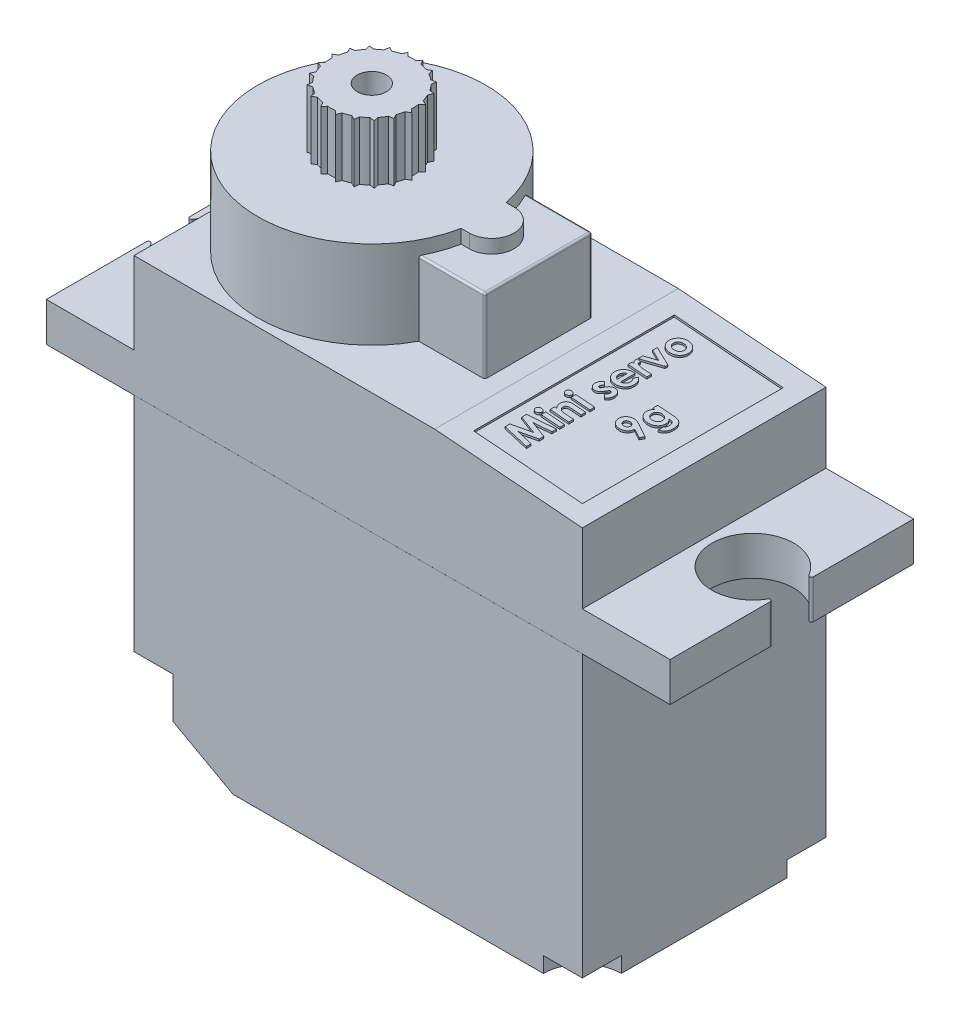
from build123d import *

# Parameters (mm, degrees)
SKETCH1_W                    = 23
SKETCH1_H                    = 12.5
BOSS_EXTRUDE1_DEPTH          = 15.2
SKETCH2_W                    = 32
SKETCH2_H                    = 12.498058614
BOSS_EXTRUDE2_DEPTH          = 2
SKETCH3_W                    = 23
SKETCH3_H                    = 12.498058614
BOSS_EXTRUDE3_DEPTH          = 4.2
CUT_EXTRUDE1_DEPTH           = 13.5
BOSS_EXTRUDE4_DEPTH          = 4.5
SKETCH6_W                    = 4.8
SKETCH6_H                    = 5.5
BOSS_EXTRUDE5_DEPTH          = 3.8
SKETCH8_R                    = 2.35
SKETCH8_R_2                  = 0.75
BOSS_EXTRUDE8_DEPTH          = 3
CUT_EXTRUDE2_DEPTH           = 13.5
ENL_V_MAT_EXTRU_1_DEPTH      = 3
R_P_TITION_CIRCULAIRE2_COUNT = 20
SKETCH12_R                   = 2.1
CUT_EXTRUDE11_DEPTH          = 10
CUT_EXTRUDE12_DEPTH          = 0.8
CUT_EXTRUDE13_DEPTH          = 3.8
SKETCH17_W                   = 5.6
SKETCH17_H                   = 10.3
CUT_EXTRUDE14_DEPTH          = 0.1
SKETCH19_W                   = 0.966746795
SKETCH19_H                   = 0.237446581
BOSS_EXTRUDE9_DEPTH          = 0.1
FILLET3_R                    = 0.1


with BuildPart() as part:
    # Sketch1 → Boss-Extrude1 (new body)
    with BuildSketch(Plane(origin=(0, 0, 0), x_dir=(1, 0, 0), z_dir=(0, 1, 0))):
        Rectangle(SKETCH1_W, SKETCH1_H)
    extrude(amount=BOSS_EXTRUDE1_DEPTH)

    # Sketch2 → Boss-Extrude2 (add)
    with BuildSketch(Plane(origin=(0, 15.2, 0), x_dir=(1, 0, 0), z_dir=(0, 1, 0))):
        Rectangle(SKETCH2_W, SKETCH2_H)
    extrude(amount=BOSS_EXTRUDE2_DEPTH)

    # Sketch3 → Boss-Extrude3 (add)
    with BuildSketch(Plane(origin=(0, 17.2, 0), x_dir=(1, 0, 0), z_dir=(0, 1, 0))):
        Rectangle(SKETCH3_W, SKETCH3_H)
    extrude(amount=BOSS_EXTRUDE3_DEPTH)

    # Sketch4 → Cut-Extrude1 (cut, through all)
    with BuildSketch(Plane.XY.offset(6.25)):
        Polygon((11.5, 20.8), (3.92372123, 21.4), (11.5, 21.4), align=None)
    extrude(amount=-CUT_EXTRUDE1_DEPTH, mode=Mode.SUBTRACT)

    # Sketch5 → Boss-Extrude4 (add)
    with BuildSketch(Plane(origin=(0, 21.4, 0), x_dir=(1, 0, 0), z_dir=(0, 1, 0))):
        with BuildLine():
            Line((0.18585216, 1.15), (0.6, 1.15))
            ThreePointArc((0.6, 1.15), (1.75, 0), (0.6, -1.15))
            Line((0.6, -1.15), (0.18585216, -1.15))
            ThreePointArc((0.18585216, -1.15), (-11.4, 0), (0.18585216, 1.15))
        make_face()
    extrude(amount=BOSS_EXTRUDE4_DEPTH)

    # Sketch6 → Boss-Extrude5 (add)
    with BuildSketch(Plane(origin=(0, 21.4, 0), x_dir=(1, 0, 0), z_dir=(0, 1, 0))):
        with Locations((0.6, 0)):
            Rectangle(SKETCH6_W, SKETCH6_H)
    extrude(amount=BOSS_EXTRUDE5_DEPTH)

    # Sketch9 → Cut-Extrude2 (cut, through all)
    with BuildSketch(Plane.XY.offset(6.25)):
        Polygon((-11.5, 0), (-6.42062996, 0), (-11.5, 2.8), align=None)
    extrude(amount=-CUT_EXTRUDE2_DEPTH, mode=Mode.SUBTRACT)

    # Sketch12 → Cut-Extrude11 (cut)
    with BuildSketch(Plane(origin=(0, 17.2, 0), x_dir=(1, 0, 0), z_dir=(0, 1, 0))):
        with Locations((14, 0)):
            Circle(SKETCH12_R)
    cut_extrude11 = extrude(amount=-CUT_EXTRUDE11_DEPTH, mode=Mode.SUBTRACT)

    # Mirror1: Cut-Extrude11 across plane
    add(cut_extrude11.mirror(Plane(origin=(0, 0, 0), x_dir=(0, 0, 1), z_dir=(1, 0, 0))), mode=Mode.SUBTRACT)

    # Sketch15 → Cut-Extrude12 (cut)
    with BuildSketch(Plane.XZ):
        with BuildLine():
            Line((9.5, 6.25), (11.5, 6.25))
            Line((11.5, 6.25), (11.5, 4.25))
            ThreePointArc((11.5, 4.25), (10.085786438, 4.835786438), (9.5, 6.25))
        make_face()
        with BuildLine():
            Line((11.5, -6.25), (11.5, -4.25))
            ThreePointArc((11.5, -4.25), (10.085786438, -4.835786438), (9.5, -6.25))
            Line((9.5, -6.25), (11.5, -6.25))
        make_face()
    extrude(amount=-CUT_EXTRUDE12_DEPTH, mode=Mode.SUBTRACT)

    # Sketch16 → Cut-Extrude13 (cut)
    with BuildSketch(Plane.XZ):
        with BuildLine():
            Line((-11.5, 4.25), (-11.5, 6.25))
            Line((-11.5, 6.25), (-9.5, 6.25))
            ThreePointArc((-9.5, 6.25), (-10.085786438, 4.835786438), (-11.5, 4.25))
        make_face()
        with BuildLine():
            Line((-11.5, -6.25), (-9.5, -6.25))
            ThreePointArc((-9.5, -6.25), (-10.085786438, -4.835786438), (-11.5, -4.25))
            Line((-11.5, -4.25), (-11.5, -6.25))
        make_face()
    extrude(amount=-CUT_EXTRUDE13_DEPTH, mode=Mode.SUBTRACT)

    # Sketch17 → Cut-Extrude14 (cut)
    with BuildSketch(Plane(origin=(1.708655801, 21.575421113, 0), x_dir=(0.996878786, -0.078947368, 0), z_dir=(0.078947368, 0.996878786, 0))):
        with Locations((6.02200077, -0.1)):
            Rectangle(SKETCH17_W, SKETCH17_H)
    extrude(amount=-CUT_EXTRUDE14_DEPTH, mode=Mode.SUBTRACT)

    # Sketch19 → Boss-Extrude9 (add)
    with BuildSketch(Plane(origin=(1.700761064, 21.475733235, 0), x_dir=(0.996878786, -0.078947368, 0), z_dir=(0.078947368, 0.996878786, 0))):
        Polygon((3.804977761, -4.209998915), (3.804977761, -3.963542084), (4.727733337, -3.661698718), (3.804977761, -3.357735293), (3.804977761, -3.113663528), (5.127894428, -2.889997329), (5.127894428, -3.130358991), (4.292326269, -3.271607906), (5.127894428, -3.54668553), (5.127894428, -3.77830195), (4.292326269, -4.05178953), (5.127894428, -4.192773437), (5.127894428, -4.433400107), align=None)
        with BuildLine():
            add(Edge.make_bspline(
                [(3.754096351, -2.602199352), (3.75459237, -2.591961906), (3.755566352, -2.571859693), (3.765250821, -2.543162418), (3.779962144, -2.516577279), (3.800736934, -2.493321996), (3.825461159, -2.473783527), (3.853306295, -2.459094906), (3.884008461, -2.450748481), (3.905189995, -2.449608003), (3.916015839, -2.449025107)],
                knots=[0, 0, 0, 0, 0.989451283, 1.942882919, 2.90538868, 3.918974235, 4.943608841, 5.947266847, 6.950851762, 8, 8, 8, 8], degree=3))
            add(Edge.make_bspline(
                [(3.916015839, -2.449025107), (3.926755073, -2.449605165), (3.947766142, -2.450740036), (3.978075272, -2.459095732), (4.005632722, -2.473557801), (4.02994352, -2.493040352), (4.050299111, -2.516159468), (4.065658572, -2.542001345), (4.074734342, -2.570515674), (4.075802775, -2.590299071), (4.076345283, -2.600344301)],
                knots=[0, 0, 0, 0, 1.052878812, 2.059933557, 3.056041729, 4.085953482, 5.099252665, 6.062359416, 7.016142401, 8, 8, 8, 8], degree=3))
            add(Edge.make_bspline(
                [(4.076345283, -2.600344301), (4.075838926, -2.610664087), (4.074844674, -2.630927394), (4.065284296, -2.66004514), (4.049948219, -2.686657776), (4.028907377, -2.710017641), (4.004029509, -2.729557175), (3.975889403, -2.743906483), (3.945069935, -2.752707621), (3.923583116, -2.753769392), (3.912570743, -2.754313568)],
                knots=[0, 0, 0, 0, 0.989481277, 1.942885557, 2.912973099, 3.923546742, 4.946144057, 5.937372893, 6.942867345, 8, 8, 8, 8], degree=3))
            add(Edge.make_bspline(
                [(3.912570743, -2.754313568), (3.902009274, -2.753725713), (3.881262794, -2.752570957), (3.851287745, -2.744252881), (3.824083661, -2.729750005), (3.799821827, -2.710462573), (3.779512344, -2.687309295), (3.764886508, -2.660902407), (3.755672611, -2.632306853), (3.754627196, -2.61233881), (3.754096351, -2.602199352)],
                knots=[0, 0, 0, 0, 1.038616768, 2.040212704, 3.031499824, 4.052181184, 5.074969369, 6.039807101, 7.004644834, 8, 8, 8, 8], degree=3))
        make_face()
        with Locations((4.64452103, -2.601669338)):
            Rectangle(SKETCH19_W, SKETCH19_H)
        with BuildLine():
            Line((4.161147633, -2.262459936), (4.161147633, -2.025013355))
            Line((4.161147633, -2.025013355), (4.263440468, -2.025013355))
            add(Edge.make_bspline(
                [(4.263440468, -2.025013355), (4.252895408, -2.011471852), (4.232741746, -1.985591407), (4.207153626, -1.946137744), (4.185757128, -1.909151347), (4.169870375, -1.873291895), (4.158236054, -1.838291066), (4.150419303, -1.80328736), (4.145017255, -1.768035338), (4.144463712, -1.744302244), (4.144187163, -1.732445246)],
                knots=[0, 0, 0, 0, 1.276368674, 2.439388659, 3.495912974, 4.452193402, 5.352134101, 6.235408687, 7.118414254, 8, 8, 8, 8], degree=3))
            add(Edge.make_bspline(
                [(4.144187163, -1.732445246), (4.144472419, -1.720413512), (4.145032681, -1.696782417), (4.15005373, -1.662119501), (4.157614767, -1.628794919), (4.16856507, -1.59683021), (4.182668476, -1.566184116), (4.199989685, -1.537046684), (4.220179715, -1.50914136), (4.235873487, -1.492194884), (4.243829925, -1.483603349)],
                knots=[0, 0, 0, 0, 1.049021809, 2.060345963, 3.049166385, 4.026358373, 5.002121295, 5.98669893, 6.979295433, 8, 8, 8, 8], degree=3))
            add(Edge.make_bspline(
                [(4.243829925, -1.483603349), (4.251177599, -1.476696585), (4.265926724, -1.46283251), (4.291171464, -1.445399264), (4.318743463, -1.430347031), (4.348923799, -1.41826973), (4.381735287, -1.409035118), (4.416900166, -1.402131615), (4.454686424, -1.39820407), (4.480649169, -1.397723188), (4.493996859, -1.397475962)],
                knots=[0, 0, 0, 0, 0.889614892, 1.785740703, 2.700456201, 3.659579934, 4.649837014, 5.707163549, 6.821231365, 8, 8, 8, 8], degree=3))
            Line((4.493996859, -1.397475962), (5.127894428, -1.397475962))
            Line((5.127894428, -1.397475962), (5.127894428, -1.634922543))
            Line((5.127894428, -1.634922543), (4.708122793, -1.634922543))
            add(Edge.make_bspline(
                [(4.708122793, -1.634922543), (4.694430569, -1.634972733), (4.668191963, -1.635068913), (4.630640648, -1.635808044), (4.596726682, -1.637249596), (4.566389395, -1.638567758), (4.53973313, -1.64113921), (4.516512884, -1.64350685), (4.496996733, -1.64701419), (4.476038704, -1.651710565), (4.453705894, -1.659720001), (4.43031827, -1.672584349), (4.410099694, -1.688292983), (4.393521681, -1.707140929), (4.380279706, -1.728484577), (4.371449805, -1.75249671), (4.365584458, -1.778628512), (4.36498473, -1.796895655), (4.364673274, -1.806382295)],
                knots=[0, 0, 0, 0, 1.498383532, 2.871373928, 4.109666627, 5.213205893, 6.19342024, 7.03996831, 7.766265273, 8.361852474, 9.389264387, 10.349785296, 11.272242184, 12.176177448, 13.083054194, 14.00404103, 14.963442479, 16, 16, 16, 16], degree=3))
            add(Edge.make_bspline(
                [(4.364673274, -1.806382295), (4.365300058, -1.818714845), (4.366526168, -1.84283971), (4.375733221, -1.877747918), (4.391472627, -1.909699074), (4.412865203, -1.938806589), (4.439740262, -1.964369847), (4.471892035, -1.985267733), (4.508285748, -2.002626573), (4.534841665, -2.010043608), (4.548588372, -2.013883046)],
                knots=[0, 0, 0, 0, 0.983981849, 1.924859783, 2.858520091, 3.812106071, 4.794873939, 5.802260736, 6.862337274, 8, 8, 8, 8], degree=3))
            add(Edge.make_bspline(
                [(4.548588372, -2.013883046), (4.552904782, -2.014838435), (4.562531244, -2.016969143), (4.578794152, -2.018720308), (4.598175752, -2.021173637), (4.620852782, -2.02205164), (4.646799373, -2.02367027), (4.675967638, -2.024244313), (4.708473615, -2.024836211), (4.731177961, -2.024952351), (4.743103763, -2.025013355)],
                knots=[0, 0, 0, 0, 0.543362486, 1.211807592, 2.009706767, 2.945681277, 4.000992949, 5.207456884, 6.533174374, 8, 8, 8, 8], degree=3))
            Line((4.743103763, -2.025013355), (5.127894428, -2.025013355))
            Line((5.127894428, -2.025013355), (5.127894428, -2.262459936))
            Line((5.127894428, -2.262459936), (4.161147633, -2.262459936))
        make_face()
        with BuildLine():
            add(Edge.make_bspline(
                [(3.754096351, -1.058796575), (3.75459237, -1.048559128), (3.755566352, -1.028456916), (3.765250821, -0.99975964), (3.779962144, -0.973174502), (3.800736934, -0.949919219), (3.825461159, -0.930380749), (3.853306295, -0.915692128), (3.884008461, -0.907345704), (3.905189995, -0.906205225), (3.916015839, -0.905622329)],
                knots=[0, 0, 0, 0, 0.989451283, 1.942882919, 2.90538868, 3.918974235, 4.943608841, 5.947266847, 6.950851762, 8, 8, 8, 8], degree=3))
            add(Edge.make_bspline(
                [(3.916015839, -0.905622329), (3.926755073, -0.906202387), (3.947766142, -0.907337258), (3.978075272, -0.915692954), (4.005632722, -0.930155023), (4.02994352, -0.949637574), (4.050299111, -0.97275669), (4.065658572, -0.998598568), (4.074734342, -1.027112897), (4.075802775, -1.046896293), (4.076345283, -1.056941523)],
                knots=[0, 0, 0, 0, 1.052878812, 2.059933557, 3.056041729, 4.085953482, 5.099252665, 6.062359416, 7.016142401, 8, 8, 8, 8], degree=3))
            add(Edge.make_bspline(
                [(4.076345283, -1.056941523), (4.075838926, -1.067261309), (4.074844674, -1.087524616), (4.065284296, -1.116642362), (4.049948219, -1.143254998), (4.028907377, -1.166614864), (4.004029509, -1.186154397), (3.975889403, -1.200503706), (3.945069935, -1.209304843), (3.923583116, -1.210366614), (3.912570743, -1.210910791)],
                knots=[0, 0, 0, 0, 0.989481277, 1.942885557, 2.912973099, 3.923546742, 4.946144057, 5.937372893, 6.942867345, 8, 8, 8, 8], degree=3))
            add(Edge.make_bspline(
                [(3.912570743, -1.210910791), (3.902009274, -1.210322936), (3.881262794, -1.209168179), (3.851287745, -1.200850104), (3.824083661, -1.186347227), (3.799821827, -1.167059795), (3.779512344, -1.143906517), (3.764886508, -1.117499629), (3.755672611, -1.088904075), (3.754627196, -1.068936033), (3.754096351, -1.058796575)],
                knots=[0, 0, 0, 0, 1.038616768, 2.040212704, 3.031499824, 4.052181184, 5.074969369, 6.039807101, 7.004644834, 8, 8, 8, 8], degree=3))
        make_face()
        with Locations((4.64452103, -1.05826656)):
            Rectangle(SKETCH19_W, SKETCH19_H)
        with BuildLine():
            Line((4.310346768, 0.383373397), (4.466436095, 0.238149372))
            add(Edge.make_bspline(
                [(4.466436095, 0.238149372), (4.458411661, 0.230897641), (4.443063959, 0.217027826), (4.42214161, 0.19579448), (4.404719475, 0.17487734), (4.390084155, 0.154666195), (4.378860614, 0.134748261), (4.370785527, 0.115289102), (4.365659342, 0.09627938), (4.364995777, 0.083678933), (4.364673274, 0.077554921)],
                knots=[0, 0, 0, 0, 1.327646587, 2.539285, 3.655602211, 4.666613517, 5.598770349, 6.454635452, 7.248928967, 8, 8, 8, 8], degree=3))
            add(Edge.make_bspline(
                [(4.364673274, 0.077554921), (4.364862134, 0.071358036), (4.365223742, 0.05949293), (4.36832543, 0.042748605), (4.373695023, 0.028037596), (4.38101428, 0.015589477), (4.390030852, 0.005588438), (4.400345598, -0.001413756), (4.411637705, -0.006115794), (4.419658925, -0.006513556), (4.423769912, -0.006717415)],
                knots=[0, 0, 0, 0, 1.295068245, 2.479652818, 3.543291146, 4.55379989, 5.481948265, 6.332409746, 7.145336708, 8, 8, 8, 8], degree=3))
            add(Edge.make_bspline(
                [(4.423769912, -0.006717415), (4.429999834, -0.006026723), (4.442926199, -0.004593619), (4.457918854, 0.005249822), (4.468978629, 0.018273405), (4.479270384, 0.033285831), (4.490777669, 0.053616541), (4.498657043, 0.069039934), (4.503007108, 0.077554921)],
                knots=[0, 0, 0, 0, 0.916701701, 1.902049539, 2.5493345, 3.440293453, 4.586830489, 6, 6, 6, 6], degree=3))
            Line((4.503007108, 0.077554921), (4.546468313, 0.163417301))
            add(Edge.make_bspline(
                [(4.546468313, 0.163417301), (4.552012371, 0.174342414), (4.562768887, 0.195539185), (4.580166995, 0.22531091), (4.596910375, 0.2529569), (4.614548494, 0.277363506), (4.6315577, 0.299650815), (4.649266113, 0.318725676), (4.66663527, 0.335555581), (4.689956301, 0.354300833), (4.721007202, 0.37305852), (4.761391978, 0.388694119), (4.804634, 0.398665374), (4.834563654, 0.399768531), (4.849901723, 0.400333868)],
                knots=[0, 0, 0, 0, 1.076723934, 2.08904669, 3.030727471, 3.916304557, 4.734969869, 5.493452046, 6.201990317, 6.859314016, 8.120513813, 9.372210561, 10.65333501, 12, 12, 12, 12], degree=3))
            add(Edge.make_bspline(
                [(4.849901723, 0.400333868), (4.860249279, 0.399992958), (4.880502193, 0.399325709), (4.910315033, 0.395114986), (4.938653049, 0.387529508), (4.96592948, 0.377647433), (4.991566802, 0.364076491), (5.015941096, 0.347877032), (5.039267105, 0.32895112), (5.060771519, 0.306951087), (5.08069072, 0.282714428), (5.097975095, 0.256157985), (5.112234484, 0.227511698), (5.124309895, 0.197156425), (5.133541298, 0.164651356), (5.140075024, 0.130151664), (5.144149087, 0.093641178), (5.144615633, 0.068643987), (5.144854898, 0.055824319)],
                knots=[0, 0, 0, 0, 0.976822692, 1.911901239, 2.834103221, 3.741677305, 4.644181532, 5.564572461, 6.500876952, 7.4737059, 8.463396961, 9.457853255, 10.457191201, 11.479092582, 12.537356171, 13.641151563, 14.790277904, 16, 16, 16, 16], degree=3))
            add(Edge.make_bspline(
                [(5.144854898, 0.055824319), (5.144314006, 0.038838887), (5.143252284, 0.005497979), (5.135856475, -0.043194003), (5.123054206, -0.08917216), (5.105119865, -0.132474321), (5.082266598, -0.173365705), (5.053910696, -0.211262336), (5.02079095, -0.246821188), (4.995389648, -0.267509698), (4.982405396, -0.278084936)],
                knots=[0, 0, 0, 0, 1.056901255, 2.07460411, 3.05625841, 4.019970729, 4.984811261, 5.963335951, 6.958928997, 8, 8, 8, 8], degree=3))
            Line((4.982405396, -0.278084936), (4.822605966, -0.134185948))
            add(Edge.make_bspline(
                [(4.822605966, -0.134185948), (4.829976995, -0.127155304), (4.844652167, -0.113157812), (4.864364835, -0.089970439), (4.881622161, -0.064861726), (4.896561886, -0.038529818), (4.908343449, -0.011961111), (4.917871849, 0.013266089), (4.922989826, 0.037245738), (4.923924579, 0.052713802), (4.924368787, 0.060064436)],
                knots=[0, 0, 0, 0, 1.087612404, 2.16535591, 3.243760151, 4.338105798, 5.393939541, 6.346052752, 7.214021764, 8, 8, 8, 8], degree=3))
            add(Edge.make_bspline(
                [(4.924368787, 0.060064436), (4.924155729, 0.067418104), (4.923746173, 0.081553884), (4.919488871, 0.101646665), (4.912325846, 0.11944803), (4.902413191, 0.134570882), (4.891022432, 0.147005385), (4.878231414, 0.156115914), (4.86438933, 0.161763388), (4.854721202, 0.162513408), (4.849901723, 0.162887286)],
                knots=[0, 0, 0, 0, 1.254755047, 2.411985499, 3.488053563, 4.513519474, 5.48505018, 6.351651985, 7.178312628, 8, 8, 8, 8], degree=3))
            add(Edge.make_bspline(
                [(4.849901723, 0.162887286), (4.845356364, 0.162568182), (4.836023866, 0.161913), (4.822248431, 0.1567259), (4.80860854, 0.148582051), (4.795065737, 0.137286977), (4.781729904, 0.122690382), (4.768707857, 0.104844504), (4.755304854, 0.084161048), (4.747305057, 0.068883071), (4.743103763, 0.060859458)],
                knots=[0, 0, 0, 0, 0.704666567, 1.446816302, 2.258757648, 3.165368109, 4.175243826, 5.322435858, 6.59381024, 8, 8, 8, 8], degree=3))
            Line((4.743103763, 0.060859458), (4.703352661, -0.017847723))
            add(Edge.make_bspline(
                [(4.703352661, -0.017847723), (4.693778669, -0.035701654), (4.675400194, -0.069974507), (4.643885016, -0.116298592), (4.610336481, -0.155505243), (4.574934824, -0.187626409), (4.537779391, -0.213220617), (4.498397119, -0.231074295), (4.457161363, -0.242305889), (4.428963906, -0.243541544), (4.414759662, -0.244163996)],
                knots=[0, 0, 0, 0, 1.255999728, 2.41104856, 3.467751088, 4.449286722, 5.368722015, 6.253902015, 7.120417131, 8, 8, 8, 8], degree=3))
            add(Edge.make_bspline(
                [(4.414759662, -0.244163996), (4.4055536, -0.243948499), (4.387480604, -0.243525443), (4.360942704, -0.239008963), (4.335419189, -0.232212753), (4.310862392, -0.222494372), (4.287146379, -0.210434323), (4.264810914, -0.194978347), (4.243198378, -0.177225831), (4.223001804, -0.156666391), (4.204607635, -0.13400435), (4.188229119, -0.109823584), (4.174713643, -0.083892204), (4.163557278, -0.056471932), (4.154767991, -0.027568018), (4.148768284, 0.002889111), (4.144959167, 0.034792376), (4.144448144, 0.056608233), (4.144187163, 0.067749649)],
                knots=[0, 0, 0, 0, 0.958838075, 1.882354927, 2.798264616, 3.708042778, 4.63064089, 5.565475101, 6.533511613, 7.542848948, 8.564005966, 9.572881083, 10.582092379, 11.606441752, 12.655212552, 13.726187313, 14.838757778, 16, 16, 16, 16], degree=3))
            add(Edge.make_bspline(
                [(4.144187163, 0.067749649), (4.14465733, 0.08316049), (4.145591007, 0.113763994), (4.154281028, 0.158729483), (4.1674315, 0.202421445), (4.186430722, 0.244247137), (4.210096034, 0.283950892), (4.238892919, 0.320568862), (4.272048301, 0.354367016), (4.297453842, 0.37360859), (4.310346768, 0.383373397)],
                knots=[0, 0, 0, 0, 0.996674327, 1.979238371, 2.954234801, 3.944803944, 4.945146381, 5.93922524, 6.954188099, 8, 8, 8, 8], degree=3))
        make_face()
        with BuildLine():
            Line((4.703882676, 1.569811281), (4.703882676, 0.80738515))
            add(Edge.make_bspline(
                [(4.703882676, 0.80738515), (4.712740184, 0.808943586), (4.730145885, 0.812006038), (4.755373315, 0.818563015), (4.779130002, 0.827218054), (4.801611091, 0.837172271), (4.822737029, 0.848820193), (4.84222609, 0.862574105), (4.860479341, 0.877834698), (4.877229835, 0.894891072), (4.892283044, 0.913306255), (4.905369645, 0.933130455), (4.916540495, 0.954040769), (4.925556522, 0.976275954), (4.932788557, 0.999657643), (4.937750559, 1.024340866), (4.940688078, 1.050237284), (4.941112374, 1.067879601), (4.941329257, 1.07689762)],
                knots=[0, 0, 0, 0, 1.091578896, 2.145038655, 3.15928737, 4.157766048, 5.127497078, 6.082469626, 7.049112333, 8.012179284, 8.980248595, 9.932024523, 10.891502393, 11.853374471, 12.840501167, 13.858428296, 14.905317556, 16, 16, 16, 16], degree=3))
            add(Edge.make_bspline(
                [(4.941329257, 1.07689762), (4.941041875, 1.087782888), (4.940475936, 1.109219187), (4.935456898, 1.140623525), (4.927875861, 1.170996094), (4.916602223, 1.200049463), (4.902568525, 1.22812017), (4.885084264, 1.254746084), (4.864660388, 1.28038808), (4.848917672, 1.296032719), (4.840891473, 1.304008914)],
                knots=[0, 0, 0, 0, 1.021034703, 2.010718019, 2.977989445, 3.954245119, 4.929443971, 5.918328161, 6.938689359, 8, 8, 8, 8], degree=3))
            Line((4.840891473, 1.304008914), (4.935499095, 1.502764423))
            add(Edge.make_bspline(
                [(4.935499095, 1.502764423), (4.944146395, 1.496506806), (4.961280701, 1.484107568), (4.985391064, 1.463864728), (5.007894909, 1.44274586), (5.028607158, 1.420708481), (5.047570511, 1.397861302), (5.064561851, 1.373878538), (5.079870497, 1.348958325), (5.093835037, 1.323229223), (5.105669271, 1.296186971), (5.116408458, 1.268236713), (5.124990924, 1.238834091), (5.132595099, 1.208391768), (5.137996385, 1.176570222), (5.141989872, 1.143585618), (5.144416043, 1.109353309), (5.144706875, 1.08608846), (5.144854898, 1.074247546)],
                knots=[0, 0, 0, 0, 1.028314656, 2.037567674, 3.031191483, 4.000749816, 4.950067458, 5.890142325, 6.830371341, 7.767241903, 8.708472269, 9.672897555, 10.650494123, 11.658022535, 12.6950382, 13.758274885, 14.859048076, 16, 16, 16, 16], degree=3))
            add(Edge.make_bspline(
                [(5.144854898, 1.074247546), (5.1444835, 1.056030143), (5.143756138, 1.020352408), (5.137005181, 0.968167271), (5.125811366, 0.918605866), (5.110595094, 0.871528247), (5.090504848, 0.827137916), (5.06593281, 0.785412903), (5.037350076, 0.745936317), (5.004156771, 0.709914387), (4.968027831, 0.677097346), (4.929227817, 0.648272897), (4.888027809, 0.624153009), (4.844700478, 0.604345272), (4.799134923, 0.588950011), (4.75131126, 0.57785092), (4.701252331, 0.571047045), (4.667156612, 0.570312193), (4.649821177, 0.569938568)],
                knots=[0, 0, 0, 0, 1.103565453, 2.161269334, 3.182010356, 4.179077853, 5.15417608, 6.128274628, 7.109042802, 8.101804412, 9.090965879, 10.063106201, 11.02526161, 11.978650795, 12.945248442, 13.93468508, 14.949922959, 16, 16, 16, 16], degree=3))
            add(Edge.make_bspline(
                [(4.649821177, 0.569938568), (4.632045227, 0.57031587), (4.597071844, 0.571058193), (4.545857031, 0.577792339), (4.496991172, 0.588980696), (4.450406974, 0.604420992), (4.405958742, 0.623928243), (4.364035343, 0.648355015), (4.324490825, 0.677083042), (4.28751018, 0.70978186), (4.254131107, 0.74595639), (4.224383683, 0.784395246), (4.199596154, 0.825530327), (4.179567847, 0.868896362), (4.163295352, 0.914215964), (4.152467366, 0.962012964), (4.145197022, 1.011923702), (4.144527468, 1.046041583), (4.144187163, 1.063382245)],
                knots=[0, 0, 0, 0, 1.079208495, 2.12329425, 3.130605359, 4.119693003, 5.099659317, 6.073216462, 7.060498243, 8.06384408, 9.066070512, 10.045757761, 11.010926815, 11.975797609, 12.942977511, 13.929384301, 14.947594487, 16, 16, 16, 16], degree=3))
            add(Edge.make_bspline(
                [(4.144187163, 1.063382245), (4.144563588, 1.081687281), (4.145302659, 1.117627333), (4.152009186, 1.170170851), (4.163233887, 1.220079591), (4.178441937, 1.267424143), (4.19854815, 1.312065881), (4.223017494, 1.354042689), (4.251792289, 1.393548424), (4.28490249, 1.429987521), (4.321525451, 1.462992516), (4.361376792, 1.491925134), (4.404138733, 1.516308875), (4.449707993, 1.536287588), (4.498057821, 1.551651519), (4.549143965, 1.562765234), (4.603175099, 1.569515997), (4.640172749, 1.570237346), (4.659096435, 1.570606303)],
                knots=[0, 0, 0, 0, 1.079872682, 2.120218721, 3.119312641, 4.09522257, 5.049536469, 6.002625154, 6.957707571, 7.928326539, 8.90281534, 9.8621136, 10.828748856, 11.802121596, 12.792912577, 13.817453306, 14.883663456, 16, 16, 16, 16], degree=3))
            Line((4.659096435, 1.570606303), (4.703882676, 1.569811281))
        make_face()
        with BuildLine():
            add(Edge.make_bspline(
                [(4.517317505, 1.333159722), (4.505212802, 1.328698144), (4.481216317, 1.319853467), (4.448235811, 1.299469926), (4.41926924, 1.273052621), (4.39389435, 1.241853747), (4.373111704, 1.206462071), (4.358688893, 1.167493173), (4.349189126, 1.126024733), (4.348211629, 1.097357114), (4.347712804, 1.082727781)],
                knots=[0, 0, 0, 0, 0.954438688, 1.892088801, 2.851790463, 3.847769608, 4.862932653, 5.878306815, 6.917281712, 8, 8, 8, 8], degree=3))
            add(Edge.make_bspline(
                [(4.347712804, 1.082727781), (4.348379385, 1.066772716), (4.349681364, 1.035608994), (4.359768606, 0.990414475), (4.376339034, 0.948195595), (4.39259033, 0.923045445), (4.400714273, 0.910473007)],
                knots=[0, 0, 0, 0, 1.045043327, 2.041197553, 3.020804202, 4, 4, 4, 4], degree=3))
            add(Edge.make_bspline(
                [(4.400714273, 0.910473007), (4.40699967, 0.902630092), (4.42044218, 0.885856536), (4.447433826, 0.86444999), (4.479653579, 0.842821254), (4.504245551, 0.830757926), (4.517317505, 0.82434562)],
                knots=[0, 0, 0, 0, 0.821695496, 1.757351177, 2.807911704, 4, 4, 4, 4], degree=3))
            Line((4.517317505, 0.82434562), (4.517317505, 1.333159722))
        make_face(mode=Mode.SUBTRACT)
        with BuildLine():
            Line((4.161147633, 1.740211004), (4.161147633, 1.943736645))
            Line((4.161147633, 1.943736645), (4.280135931, 1.943736645))
            add(Edge.make_bspline(
                [(4.280135931, 1.943736645), (4.269556408, 1.949489116), (4.248878291, 1.960732558), (4.221154724, 1.981510672), (4.197505641, 2.005071327), (4.178081803, 2.03116298), (4.162790597, 2.059356218), (4.152393538, 2.089298761), (4.145264799, 2.1203407), (4.144548962, 2.141568482), (4.144187163, 2.152297426)],
                knots=[0, 0, 0, 0, 1.098257011, 2.14658889, 3.150171462, 4.135608708, 5.106151504, 6.065202199, 7.022114616, 8, 8, 8, 8], degree=3))
            add(Edge.make_bspline(
                [(4.144187163, 2.152297426), (4.144518711, 2.160092883), (4.145194538, 2.175983156), (4.150045772, 2.200036549), (4.157313776, 2.224697803), (4.164407907, 2.240790707), (4.168037824, 2.249025107)],
                knots=[0, 0, 0, 0, 0.931681262, 1.899140464, 2.92503444, 4, 4, 4, 4], degree=3))
            Line((4.168037824, 2.249025107), (4.369178399, 2.175353065))
            add(Edge.make_bspline(
                [(4.369178399, 2.175353065), (4.365996735, 2.168767836), (4.360016431, 2.156390142), (4.352959057, 2.138419878), (4.348652992, 2.122111119), (4.34801049, 2.111771665), (4.347712804, 2.10698117)],
                knots=[0, 0, 0, 0, 1.214386998, 2.282580073, 3.20428172, 4, 4, 4, 4], degree=3))
            add(Edge.make_bspline(
                [(4.347712804, 2.10698117), (4.347908395, 2.102456885), (4.348293156, 2.093556836), (4.35164296, 2.08044029), (4.357300696, 2.067963585), (4.365032019, 2.056034329), (4.374874651, 2.044681076), (4.386765627, 2.033747849), (4.401328625, 2.02397192), (4.417585579, 2.013692371), (4.437468353, 2.004930067), (4.461209231, 1.997419777), (4.489077151, 1.990726984), (4.521221983, 1.986121721), (4.557332049, 1.981670429), (4.597672593, 1.979020938), (4.64211599, 1.977046228), (4.673139088, 1.976925489), (4.689307272, 1.976862563)],
                knots=[0, 0, 0, 0, 0.544275934, 1.070684535, 1.618381339, 2.187962168, 2.776504876, 3.424199031, 4.126721978, 4.885782074, 5.738130428, 6.734037679, 7.882403433, 9.185545758, 10.642483747, 12.263902275, 14.052872929, 16, 16, 16, 16], degree=3))
            Line((4.689307272, 1.976862563), (4.736478579, 1.977657585))
            Line((4.736478579, 1.977657585), (5.127894428, 1.977657585))
            Line((5.127894428, 1.977657585), (5.127894428, 1.740211004))
            Line((5.127894428, 1.740211004), (4.161147633, 1.740211004))
        make_face()
        Polygon((4.161147633, 2.257505342), (4.161147633, 2.499192041), (4.731708447, 2.749358974), (4.161147633, 2.999525908), (4.161147633, 3.241212607), (5.127894428, 2.817730869), (5.127894428, 2.680987079), align=None)
        with BuildLine():
            add(Edge.make_bspline(
                [(4.144187163, 3.862919838), (4.144384274, 3.874146501), (4.144774642, 3.896380379), (4.148106999, 3.929483602), (4.153336085, 3.962072464), (4.16084119, 3.994075583), (4.170048487, 4.025675187), (4.181878379, 4.056535502), (4.195261458, 4.087224595), (4.211252654, 4.116886944), (4.228573983, 4.14576456), (4.24771374, 4.173114777), (4.268422332, 4.198883295), (4.290633096, 4.222984756), (4.314363687, 4.245279241), (4.33935949, 4.266183855), (4.366153691, 4.285112902), (4.394167106, 4.302612828), (4.423204221, 4.318199612), (4.453072078, 4.331732107), (4.483355329, 4.343477505), (4.514423484, 4.352673803), (4.545866699, 4.360287521), (4.578070332, 4.365092311), (4.610703558, 4.368508186), (4.632674932, 4.368891214), (4.643726008, 4.369083868)],
                knots=[0, 0, 0, 0, 1.022405107, 2.024825386, 3.027536274, 4.026883869, 5.01725043, 6.023055913, 7.035310063, 8.064783298, 9.090097283, 10.101295518, 11.102843468, 12.099336335, 13.084064592, 14.066917206, 15.06496821, 16.069711, 17.07409931, 18.064335113, 19.055093846, 20.030042637, 21.013718342, 21.999268124, 22.993679677, 24, 24, 24, 24], degree=3))
            add(Edge.make_bspline(
                [(4.643726008, 4.369083868), (4.654863339, 4.368880303), (4.677006878, 4.368475572), (4.709948265, 4.365218831), (4.742298814, 4.359811143), (4.774193544, 4.35289633), (4.805289461, 4.343004433), (4.836110279, 4.331912089), (4.866078183, 4.31778199), (4.895661464, 4.302365348), (4.924144239, 4.285011444), (4.951051048, 4.265751159), (4.976431243, 4.245109509), (5.000422318, 4.223156854), (5.022476084, 4.199418576), (5.042904332, 4.174105043), (5.0619827, 4.147468171), (5.079256613, 4.119307527), (5.094434949, 4.089986205), (5.108119357, 4.059998057), (5.119512629, 4.029167902), (5.128803522, 3.997559499), (5.13599723, 3.965153691), (5.140884001, 3.932022018), (5.144282694, 3.898235834), (5.144662935, 3.875472034), (5.144854898, 3.863979868)],
                knots=[0, 0, 0, 0, 1.012065869, 2.012216375, 3.004733514, 3.992205109, 4.97496602, 5.968164778, 6.966799732, 7.983091762, 8.999225232, 9.995016355, 10.988052865, 11.970944933, 12.947950481, 13.92969433, 14.925485454, 15.92373309, 16.929186062, 17.924491632, 18.917690389, 19.913513875, 20.91665649, 21.931711093, 22.955836906, 24, 24, 24, 24], degree=3))
            add(Edge.make_bspline(
                [(5.144854898, 3.863979868), (5.144361022, 3.847176311), (5.143387586, 3.814056245), (5.136737867, 3.765272454), (5.12524152, 3.718429658), (5.109377995, 3.673309923), (5.088425821, 3.630329261), (5.063574482, 3.588905662), (5.033444157, 3.549875299), (4.999713438, 3.512849248), (4.962582956, 3.479183704), (4.923200715, 3.449476696), (4.881691863, 3.424506735), (4.838223134, 3.403901001), (4.792720984, 3.388014398), (4.745341284, 3.376537239), (4.695945497, 3.369870386), (4.662384774, 3.368906405), (4.645316053, 3.368416132)],
                knots=[0, 0, 0, 0, 1.030098614, 2.030340051, 3.011502429, 3.982690393, 4.9563966, 5.938096863, 6.938909888, 7.973851373, 9.005145063, 10.007012469, 10.993347251, 11.969610266, 12.95101174, 13.942698978, 14.953672802, 16, 16, 16, 16], degree=3))
            add(Edge.make_bspline(
                [(4.645316053, 3.368416132), (4.627090382, 3.368923479), (4.591268191, 3.36992066), (4.538787864, 3.377838711), (4.488540439, 3.390482985), (4.440666473, 3.408633043), (4.395077668, 3.431818146), (4.351870177, 3.460121902), (4.311034214, 3.493684191), (4.286335223, 3.519386184), (4.273775755, 3.532455679)],
                knots=[0, 0, 0, 0, 1.043912699, 2.05178951, 3.033892, 4.007821512, 4.978932272, 5.95884105, 6.962068106, 8, 8, 8, 8], degree=3))
            add(Edge.make_bspline(
                [(4.273775755, 3.532455679), (4.263365369, 3.544448248), (4.242827832, 3.568107103), (4.216779333, 3.606544956), (4.194281377, 3.64590098), (4.175783873, 3.686646874), (4.161837053, 3.728896227), (4.151685016, 3.772432535), (4.145449338, 3.817246745), (4.144610026, 3.847618106), (4.144187163, 3.862919838)],
                knots=[0, 0, 0, 0, 1.048115528, 2.067714963, 3.060638214, 4.039924844, 5.017819947, 5.994373833, 6.98952318, 8, 8, 8, 8], degree=3))
        make_face()
        with BuildLine():
            add(Edge.make_bspline(
                [(4.364673274, 3.868219985), (4.364967766, 3.859023545), (4.365547476, 3.840920252), (4.368930707, 3.814347082), (4.374970655, 3.788977887), (4.384022748, 3.764993219), (4.394672475, 3.741785332), (4.408357737, 3.720008385), (4.424430209, 3.699498317), (4.442567651, 3.680174762), (4.462846251, 3.662912363), (4.484548189, 3.647603438), (4.507545273, 3.634517821), (4.532193721, 3.624286023), (4.557952671, 3.615927215), (4.585233823, 3.610249934), (4.613753217, 3.606304657), (4.633288386, 3.606011429), (4.643195994, 3.605862714)],
                knots=[0, 0, 0, 0, 1.030405752, 2.028364813, 2.995676022, 3.944329772, 4.896127072, 5.85177522, 6.817820016, 7.811895093, 8.815529982, 9.795715103, 10.783861249, 11.772750455, 12.780524062, 13.813161006, 14.890905832, 16, 16, 16, 16], degree=3))
            add(Edge.make_bspline(
                [(4.643195994, 3.605862714), (4.653453111, 3.606036512), (4.673498677, 3.606376166), (4.702767121, 3.609896291), (4.730545607, 3.615694832), (4.756777657, 3.623954211), (4.781628773, 3.634237305), (4.804862064, 3.647112712), (4.826594713, 3.662232607), (4.846741686, 3.679464783), (4.86493274, 3.698461082), (4.88102089, 3.718860656), (4.894156089, 3.740837459), (4.90557151, 3.763647189), (4.913901521, 3.787927454), (4.920154778, 3.813269986), (4.9234952, 3.839952431), (4.924073587, 3.858141531), (4.924368787, 3.867424963)],
                knots=[0, 0, 0, 0, 1.141979911, 2.23178043, 3.277659926, 4.298338318, 5.290546728, 6.26815979, 7.25071132, 8.234641181, 9.215812446, 10.176243271, 11.121178574, 12.06282999, 13.01190517, 13.973595049, 14.965754676, 16, 16, 16, 16], degree=3))
            add(Edge.make_bspline(
                [(4.924368787, 3.867424963), (4.924107565, 3.876713394), (4.923595417, 3.894924109), (4.919760243, 3.921632876), (4.913724434, 3.947123137), (4.905206178, 3.971506972), (4.894033326, 3.994587207), (4.880348511, 4.0164523), (4.864455163, 4.037294202), (4.845844891, 4.056427033), (4.825657474, 4.074133407), (4.803770145, 4.089677394), (4.780414997, 4.102566167), (4.755723034, 4.113410131), (4.72955403, 4.121490359), (4.701958163, 4.127267782), (4.67307819, 4.131201933), (4.653279741, 4.131490376), (4.643195994, 4.131637286)],
                knots=[0, 0, 0, 0, 1.03148129, 2.022302122, 2.990961611, 3.937500375, 4.885462201, 5.833017655, 6.798640665, 7.791063629, 8.792613068, 9.77817235, 10.766512052, 11.750898281, 12.768848897, 13.802335193, 14.880685208, 16, 16, 16, 16], degree=3))
            add(Edge.make_bspline(
                [(4.643195994, 4.131637286), (4.633115411, 4.131461191), (4.613334036, 4.131115634), (4.584420095, 4.127596454), (4.556977492, 4.121850572), (4.531123404, 4.11350024), (4.506562877, 4.103193642), (4.483421629, 4.09046424), (4.461813634, 4.075181997), (4.441846038, 4.057856856), (4.423836329, 4.038695339), (4.40777604, 4.018368889), (4.394492948, 3.996412703), (4.383542938, 3.973238691), (4.375118468, 3.948785198), (4.368865039, 3.923079679), (4.36556265, 3.896043352), (4.364972831, 3.87759137), (4.364673274, 3.868219985)],
                knots=[0, 0, 0, 0, 1.123894411, 2.205445421, 3.243160173, 4.246488011, 5.231014757, 6.210004299, 7.185865357, 8.177612767, 9.153374344, 10.115157457, 11.061423229, 12.009021698, 12.96873347, 13.94135618, 14.954456845, 16, 16, 16, 16], degree=3))
        make_face(mode=Mode.SUBTRACT)
        with BuildLine():
            Line((6.554701107, 0.620819979), (6.554701107, 0.87522703))
            Line((6.554701107, 0.87522703), (7.379403965, 0.87522703))
            add(Edge.make_bspline(
                [(7.379403965, 0.87522703), (7.399111173, 0.874916189), (7.437254612, 0.874314555), (7.492416239, 0.869871399), (7.543533659, 0.862280351), (7.59064003, 0.85152902), (7.633739116, 0.83747211), (7.672926328, 0.820629152), (7.708102575, 0.800555468), (7.728686082, 0.784320277), (7.738753925, 0.77637929)],
                knots=[0, 0, 0, 0, 1.243772139, 2.407329661, 3.489955262, 4.502936921, 5.453266643, 6.347163941, 7.191561808, 8, 8, 8, 8], degree=3))
            add(Edge.make_bspline(
                [(7.738753925, 0.77637929), (7.751283479, 0.76495645), (7.776279152, 0.742168599), (7.807822806, 0.701992342), (7.834782602, 0.657977772), (7.856877446, 0.609675714), (7.873706669, 0.5571437), (7.885826708, 0.50051668), (7.89337564, 0.439758754), (7.894169872, 0.39779488), (7.894578244, 0.376218199)],
                knots=[0, 0, 0, 0, 0.916003385, 1.827369254, 2.751972866, 3.703651841, 4.69362366, 5.730423306, 6.83304546, 8, 8, 8, 8], degree=3))
            add(Edge.make_bspline(
                [(7.894578244, 0.376218199), (7.894225152, 0.353410399), (7.893546064, 0.309545125), (7.886903034, 0.246511632), (7.875972385, 0.189094194), (7.860583581, 0.137023179), (7.840727574, 0.089813469), (7.816919075, 0.046574808), (7.788454055, 0.007390235), (7.756454706, -0.028332543), (7.720218307, -0.059765048), (7.680076627, -0.086605324), (7.636398888, -0.109471843), (7.605164309, -0.120762447), (7.589289782, -0.126500735)],
                knots=[0, 0, 0, 0, 1.29412125, 2.488928388, 3.592140377, 4.607309753, 5.564519828, 6.493640275, 7.402258018, 8.307438948, 9.210158992, 10.116782752, 11.042881838, 12, 12, 12, 12], degree=3))
            Line((7.589289782, -0.126500735), (7.589289782, 0.137446581))
            add(Edge.make_bspline(
                [(7.589289782, 0.137446581), (7.596004795, 0.143546121), (7.609520155, 0.155822715), (7.626670231, 0.177536665), (7.641349859, 0.201557214), (7.65337011, 0.22807816), (7.662510432, 0.257210085), (7.669454623, 0.288754681), (7.673368038, 0.322853244), (7.673845848, 0.34635095), (7.674092133, 0.358462707)],
                knots=[0, 0, 0, 0, 0.888971165, 1.789239437, 2.70354581, 3.646217955, 4.638595249, 5.694475788, 6.811630907, 8, 8, 8, 8], degree=3))
            add(Edge.make_bspline(
                [(7.674092133, 0.358462707), (7.673761792, 0.373761388), (7.673131129, 0.402968465), (7.667731516, 0.444432585), (7.658270965, 0.481248666), (7.64496631, 0.513281339), (7.62879073, 0.540842077), (7.610079565, 0.5639756), (7.589182293, 0.582786164), (7.569770268, 0.5953273), (7.552216841, 0.602633147), (7.537059228, 0.607823605), (7.519570989, 0.611459234), (7.500075557, 0.615061921), (7.478385566, 0.617609224), (7.45442116, 0.619343865), (7.428359778, 0.620833185), (7.410235549, 0.620824478), (7.40086956, 0.620819979)],
                knots=[0, 0, 0, 0, 1.656477545, 3.162420723, 4.517622016, 5.761356219, 6.906624731, 7.967504464, 8.970189393, 9.941718189, 10.451748823, 11.026576706, 11.674113382, 12.383505882, 13.173827269, 14.037474498, 14.985833138, 16, 16, 16, 16], degree=3))
            add(Edge.make_bspline(
                [(7.40086956, 0.620819979), (7.41107193, 0.61041747), (7.430980765, 0.590118084), (7.456383704, 0.557165989), (7.477352806, 0.52343077), (7.494068777, 0.488731818), (7.506150319, 0.45231126), (7.515473783, 0.414169544), (7.52025632, 0.373512792), (7.521044892, 0.345664293), (7.521447902, 0.331431958)],
                knots=[0, 0, 0, 0, 1.081917146, 2.111245892, 3.083933414, 4.029306922, 4.965452363, 5.930245736, 6.942225358, 8, 8, 8, 8], degree=3))
            add(Edge.make_bspline(
                [(7.521447902, 0.331431958), (7.521084179, 0.315682548), (7.520369698, 0.284745122), (7.513422454, 0.239305677), (7.502621952, 0.195705662), (7.487555484, 0.153850864), (7.467645657, 0.114040188), (7.443530548, 0.076081602), (7.414794462, 0.040155124), (7.382538175, 0.006145979), (7.346729043, -0.024627412), (7.308288958, -0.05159814), (7.267603708, -0.074561301), (7.224370159, -0.093100042), (7.178959312, -0.1077421), (7.131207832, -0.118047156), (7.081168044, -0.124214066), (7.047014087, -0.125026389), (7.02959427, -0.125440705)],
                knots=[0, 0, 0, 0, 1.0076895, 1.97945953, 2.935501295, 3.880116828, 4.820983434, 5.779581085, 6.753800082, 7.761838664, 8.776439707, 9.771175274, 10.763786435, 11.761844349, 12.777721313, 13.813799342, 14.884954532, 16, 16, 16, 16], degree=3))
            add(Edge.make_bspline(
                [(7.02959427, -0.125440705), (7.011021298, -0.125082381), (6.97472274, -0.12438208), (6.921710617, -0.117480604), (6.871421263, -0.106838453), (6.823910105, -0.0913577), (6.779219022, -0.071466515), (6.737396355, -0.047090945), (6.697971496, -0.018859516), (6.674587303, 0.00350029), (6.662824104, 0.01474818)],
                knots=[0, 0, 0, 0, 1.104152292, 2.157928047, 3.174041476, 4.157659318, 5.124305854, 6.077739872, 7.033025107, 8, 8, 8, 8], degree=3))
            add(Edge.make_bspline(
                [(6.662824104, 0.01474818), (6.652766058, 0.025401965), (6.632982297, 0.04635752), (6.608009691, 0.081053532), (6.58583944, 0.116444468), (6.568466397, 0.153936575), (6.554364629, 0.192694859), (6.545175198, 0.233322698), (6.538605293, 0.275213941), (6.538030922, 0.303756331), (6.537740637, 0.318181591)],
                knots=[0, 0, 0, 0, 1.04220621, 2.049976561, 3.038199794, 4.011820125, 4.986740134, 5.969341572, 6.973709775, 8, 8, 8, 8], degree=3))
            add(Edge.make_bspline(
                [(6.537740637, 0.318181591), (6.538113166, 0.331713765), (6.538851355, 0.358528626), (6.544268521, 0.398207167), (6.553239637, 0.436743557), (6.566166359, 0.474403023), (6.583241465, 0.511460175), (6.605062979, 0.548259427), (6.631283087, 0.58523894), (6.651743489, 0.608714555), (6.662294089, 0.620819979)],
                knots=[0, 0, 0, 0, 0.967981879, 1.91811742, 2.859383259, 3.794753291, 4.761888878, 5.77319847, 6.851728731, 8, 8, 8, 8], degree=3))
            Line((6.662294089, 0.620819979), (6.554701107, 0.620819979))
        make_face()
        with BuildLine():
            add(Edge.make_bspline(
                [(6.758226748, 0.374893162), (6.758526044, 0.365610224), (6.759115279, 0.347334511), (6.762430925, 0.320473154), (6.768702461, 0.294988565), (6.776803964, 0.270537534), (6.787838123, 0.247578003), (6.800757217, 0.225528232), (6.816679623, 0.205211343), (6.834243534, 0.185805436), (6.853919464, 0.168501978), (6.875215951, 0.153595308), (6.897293061, 0.140441109), (6.920964904, 0.130188588), (6.945622962, 0.121717162), (6.97175982, 0.116538342), (6.998900252, 0.112400785), (7.017474807, 0.112139222), (7.026944196, 0.112005876)],
                knots=[0, 0, 0, 0, 1.05904976, 2.084996003, 3.07954492, 4.048086364, 5.017046909, 5.979438155, 6.956742971, 7.955010031, 8.961529674, 9.937119326, 10.916861767, 11.886607638, 12.874243659, 13.883985139, 14.921246403, 16, 16, 16, 16], degree=3))
            add(Edge.make_bspline(
                [(7.026944196, 0.112005876), (7.036764093, 0.112150208), (7.056036851, 0.112433478), (7.084113661, 0.116399512), (7.110984853, 0.122064937), (7.136322437, 0.130623018), (7.160459254, 0.141336974), (7.183383746, 0.154206815), (7.204546667, 0.170094324), (7.224418052, 0.187735355), (7.242371683, 0.207256707), (7.258032389, 0.228249338), (7.271412455, 0.250405602), (7.282425623, 0.273804783), (7.290440175, 0.298627323), (7.296764528, 0.324449137), (7.300071116, 0.351575964), (7.300661797, 0.370027254), (7.300961791, 0.379398287)],
                knots=[0, 0, 0, 0, 1.097849452, 2.154664808, 3.166713745, 4.16691636, 5.140389278, 6.118717454, 7.101230796, 8.095260774, 9.088602535, 10.063178766, 11.020918878, 11.980493352, 12.949439634, 13.934782788, 14.951118353, 16, 16, 16, 16], degree=3))
            add(Edge.make_bspline(
                [(7.300961791, 0.379398287), (7.300817673, 0.388600582), (7.300535104, 0.406643374), (7.296564334, 0.432960892), (7.290834757, 0.458112021), (7.282598567, 0.482019119), (7.271982225, 0.504709301), (7.258777484, 0.525953781), (7.243727742, 0.546354501), (7.22588282, 0.564945729), (7.206499288, 0.582137211), (7.185442706, 0.597072374), (7.16293311, 0.609601695), (7.139009742, 0.620045168), (7.113451876, 0.627859209), (7.086530428, 0.633775643), (7.058129956, 0.637250056), (7.038702351, 0.637601369), (7.028799248, 0.637780449)],
                knots=[0, 0, 0, 0, 1.047549784, 2.053914015, 3.025605288, 3.983699929, 4.929235134, 5.873483749, 6.829673207, 7.812250665, 8.803604288, 9.778262406, 10.747082322, 11.734339848, 12.746676024, 13.78709343, 14.871984244, 16, 16, 16, 16], degree=3))
            add(Edge.make_bspline(
                [(7.028799248, 0.637780449), (7.018982968, 0.637609521), (6.99981619, 0.637275776), (6.971699877, 0.633702194), (6.94508322, 0.627967714), (6.919785232, 0.619908022), (6.895906983, 0.609669038), (6.873551803, 0.596761445), (6.852442528, 0.581866415), (6.832926218, 0.564775076), (6.815522953, 0.545616063), (6.800055328, 0.525334984), (6.787204063, 0.503488567), (6.776576339, 0.480428201), (6.768314096, 0.455903598), (6.762631648, 0.430037983), (6.758652823, 0.402929931), (6.758370618, 0.384360129), (6.758226748, 0.374893162)],
                knots=[0, 0, 0, 0, 1.110974103, 2.169232699, 3.203151462, 4.190088473, 5.171179403, 6.138871241, 7.107441459, 8.092602901, 9.069555158, 10.033777349, 10.975533625, 11.933301222, 12.904347287, 13.899210009, 14.929008108, 16, 16, 16, 16], degree=3))
        make_face(mode=Mode.SUBTRACT)
        with BuildLine():
            Line((7.555368842, -0.764638421), (7.449365904, -0.975054253))
            Line((7.449365904, -0.975054253), (6.995673329, -0.744497863))
            add(Edge.make_bspline(
                [(6.995673329, -0.744497863), (6.995326102, -0.758119643), (6.994644409, -0.784862493), (6.988980355, -0.82423961), (6.979309429, -0.861893616), (6.966441935, -0.898274885), (6.94916575, -0.932855939), (6.928614732, -0.966195177), (6.903546271, -0.997422084), (6.87578922, -1.027284528), (6.84502602, -1.054297397), (6.8121561, -1.07815428), (6.777495826, -1.098355344), (6.740812287, -1.114571909), (6.702471064, -1.127308468), (6.662321754, -1.136702374), (6.620209927, -1.141958151), (6.591551165, -1.142694204), (6.576961724, -1.14306891)],
                knots=[0, 0, 0, 0, 1.014438208, 1.991587644, 2.955575466, 3.906834206, 4.860343588, 5.829907848, 6.818577787, 7.838125475, 8.863876483, 9.862937823, 10.859547262, 11.846397878, 12.845242478, 13.865236027, 14.913246352, 16, 16, 16, 16], degree=3))
            add(Edge.make_bspline(
                [(6.576961724, -1.14306891), (6.562809749, -1.142722055), (6.534923575, -1.142038583), (6.493998959, -1.136351073), (6.454692982, -1.127018703), (6.416994818, -1.114092148), (6.381096427, -1.097258853), (6.346783907, -1.076921011), (6.314188497, -1.052775662), (6.28373498, -1.025021046), (6.255746541, -0.994949421), (6.23165788, -0.962597791), (6.210633234, -0.929210877), (6.194022095, -0.89387029), (6.180521284, -0.857232601), (6.171391989, -0.818793998), (6.165638832, -0.778947196), (6.164955884, -0.751849708), (6.164610295, -0.738137687)],
                knots=[0, 0, 0, 0, 1.055350394, 2.079546115, 3.075301024, 4.065173222, 5.046874257, 6.027823047, 7.036058964, 8.067100199, 9.097720188, 10.095392023, 11.071904115, 12.035727154, 13.002945728, 13.979480054, 14.977565287, 16, 16, 16, 16], degree=3))
            add(Edge.make_bspline(
                [(6.164610295, -0.738137687), (6.164905473, -0.723803387), (6.1654859, -0.695616927), (6.171886368, -0.654354413), (6.181714746, -0.614881185), (6.195032189, -0.57701293), (6.213201797, -0.54135038), (6.23454675, -0.507214016), (6.260394672, -0.475265421), (6.289473981, -0.445340792), (6.321372675, -0.4184009), (6.35448696, -0.394382463), (6.388918862, -0.373966019), (6.424692361, -0.357657405), (6.461561653, -0.344689869), (6.499608299, -0.335854085), (6.538794901, -0.329972548), (6.565368066, -0.329304464), (6.578816776, -0.328966346)],
                knots=[0, 0, 0, 0, 1.062709067, 2.08967359, 3.089490552, 4.078335371, 5.060205664, 6.052952122, 7.060109841, 8.102908433, 9.144326257, 10.153805576, 11.135063239, 12.108674621, 13.066249871, 14.029571809, 15.002763993, 16, 16, 16, 16], degree=3))
            add(Edge.make_bspline(
                [(6.578816776, -0.328966346), (6.589073558, -0.329152046), (6.609733023, -0.329526088), (6.640629799, -0.333158039), (6.671605961, -0.338744348), (6.697697498, -0.345259228), (6.71978027, -0.35181234), (6.738460696, -0.358626482), (6.759276625, -0.366844656), (6.782260094, -0.376356724), (6.807297243, -0.387239108), (6.834301063, -0.399862748), (6.863685338, -0.41343033), (6.883777316, -0.423432622), (6.894175516, -0.428609108)],
                knots=[0, 0, 0, 0, 1.105166677, 2.22605417, 3.348517788, 4.496260522, 5.122810462, 5.830557215, 6.638607343, 7.535109037, 8.511576286, 9.580928918, 10.748058253, 12, 12, 12, 12], degree=3))
            Line((6.894175516, -0.428609108), (7.555368842, -0.764638421))
        make_face()
        with BuildLine():
            add(Edge.make_bspline(
                [(6.775187218, -0.73283754), (6.774518461, -0.72145914), (6.773211862, -0.699228324), (6.763077743, -0.667311328), (6.745788437, -0.638632247), (6.722498492, -0.613475641), (6.694499576, -0.592533843), (6.662687683, -0.577188796), (6.627569443, -0.567885433), (6.603078714, -0.566913191), (6.590477099, -0.566412927)],
                knots=[0, 0, 0, 0, 0.984989413, 1.924446292, 2.868477643, 3.865502828, 4.877610339, 5.88087679, 6.909612885, 8, 8, 8, 8], degree=3))
            add(Edge.make_bspline(
                [(6.590477099, -0.566412927), (6.577611818, -0.56701112), (6.552585776, -0.568174749), (6.516566279, -0.577638186), (6.48400679, -0.593809298), (6.455703628, -0.61580917), (6.432017496, -0.641493733), (6.414715415, -0.670215559), (6.404016363, -0.70127722), (6.402714549, -0.722772977), (6.402056876, -0.733632562)],
                knots=[0, 0, 0, 0, 1.104110315, 2.147758178, 3.172670271, 4.206310416, 5.210906102, 6.157051016, 7.068948237, 8, 8, 8, 8], degree=3))
            add(Edge.make_bspline(
                [(6.402056876, -0.733632562), (6.402699297, -0.745109323), (6.403960684, -0.76764385), (6.41461571, -0.799988287), (6.431627668, -0.82966974), (6.455102502, -0.855982824), (6.483287958, -0.87822765), (6.515951645, -0.894044884), (6.551738514, -0.903958843), (6.576806807, -0.905057864), (6.589682077, -0.905622329)],
                knots=[0, 0, 0, 0, 0.970853505, 1.906262912, 2.855477211, 3.852937491, 4.877462982, 5.878766514, 6.910518104, 8, 8, 8, 8], degree=3))
            add(Edge.make_bspline(
                [(6.589682077, -0.905622329), (6.602376471, -0.905035956), (6.627065743, -0.903895522), (6.662422066, -0.894289698), (6.694547027, -0.878790314), (6.722584623, -0.857171257), (6.745993076, -0.831173024), (6.763081413, -0.801205058), (6.773240176, -0.767929192), (6.774526521, -0.74474532), (6.775187218, -0.73283754)],
                knots=[0, 0, 0, 0, 1.075841396, 2.092399178, 3.084869331, 4.085011737, 5.078048045, 6.03490933, 6.990683323, 8, 8, 8, 8], degree=3))
        make_face(mode=Mode.SUBTRACT)
    extrude(amount=BOSS_EXTRUDE9_DEPTH)

    # Fillet3
    fillet3_edges = [part.edges().sort_by_distance(p)[0] for p in [
        (16, 16.2, 0.640312424),
        (16, 16.2, -0.640312424),
        (-16, 16.2, 0.640312424),
        (-16, 16.2, -0.640312424),
        (3, 23.3, -2.75),
        (1.306666129, 25.2, -2.75),
        (1.306666129, 25.2, 2.75),
        (3, 25.2, 0),
        (3, 23.3, 2.75),
    ]]
    fillet(fillet3_edges, radius=FILLET3_R)


with BuildPart() as body_2:
    # Sketch8 → Boss-Extrude8 (new body)
    with BuildSketch(Plane(origin=(0, 25.9, 0), x_dir=(1, 0, 0), z_dir=(0, 1, 0))):
        with Locations(Location((-5.55, 0, 0), (0, 0, 270))):  # turned: the seam where the file's is
            Circle(SKETCH8_R)
        with Locations(Location((-5.55, 0, 0), (0, 0, 270))):  # turned: the seam where the file's is
            Circle(SKETCH8_R_2, mode=Mode.SUBTRACT)
    extrude(amount=BOSS_EXTRUDE8_DEPTH)

    # Sketch14 → Enlèv. mat.-Extru.1 (cut)
    with BuildSketch(Plane(origin=(0, 28.9, 0), x_dir=(1, 0, 0), z_dir=(0, 1, 0))):
        with BuildLine():
            Line((-7.856196611, -0.451616201), (-7.682783616, -0.271540139))
            ThreePointArc((-7.682783616, -0.271540139), (-7.6985836, -0.078028919), (-7.696862004, 0.116118622))
            Line((-7.696862004, 0.116118622), (-7.882880396, 0.283141414))
            ThreePointArc((-7.882880396, 0.283141414), (-8.017969176, -0.089627868), (-7.856196611, -0.451616201))
        make_face()
    enl_v_mat_extru_1 = extrude(amount=-ENL_V_MAT_EXTRU_1_DEPTH, mode=Mode.SUBTRACT)

    # Répétition circulaire2: Enlèv. mat.-Extru.1 ×20 about axis
    r_p_tition_circulaire2_axis = Axis((-5.55, 0, 0), (0, 1, 0))
    for i in range(1, R_P_TITION_CIRCULAIRE2_COUNT):
        add(enl_v_mat_extru_1.rotate(r_p_tition_circulaire2_axis, i * 360 / R_P_TITION_CIRCULAIRE2_COUNT), mode=Mode.SUBTRACT)


solid = Compound([part.part, body_2.part])
